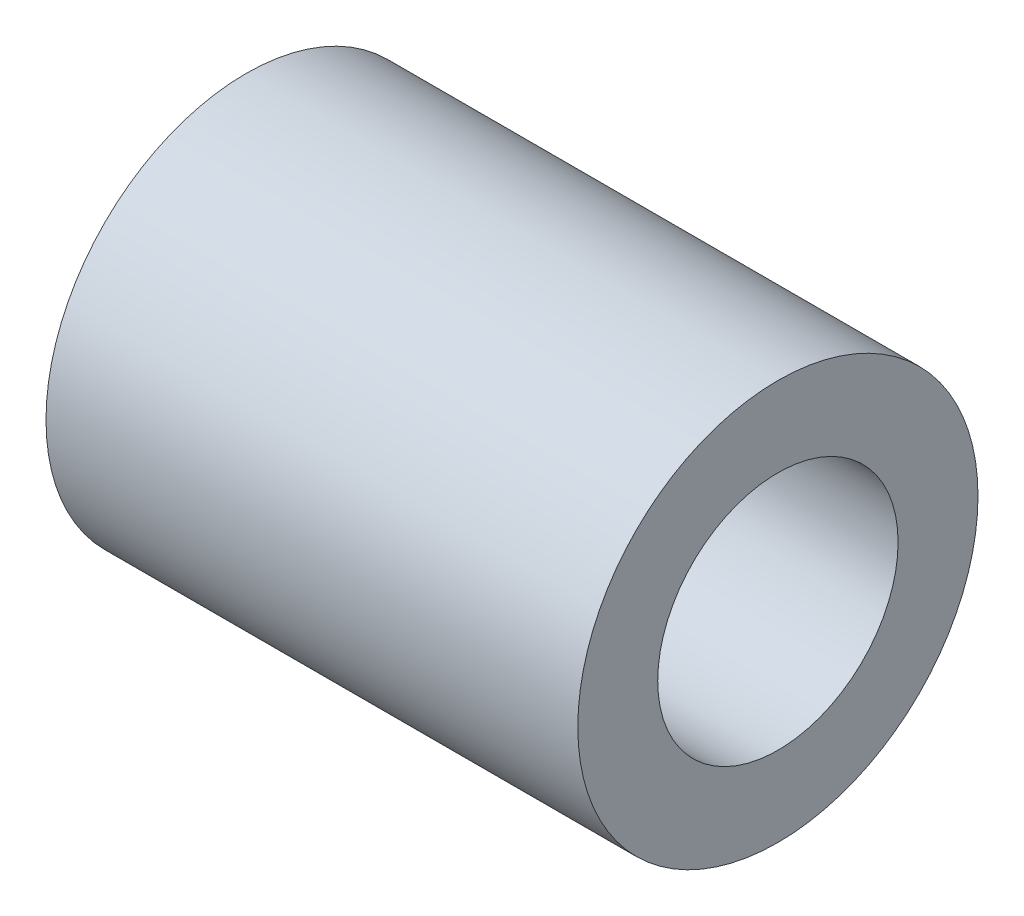
from build123d import *

# Parameters (mm, degrees)
CROQUIS1_R              = 13.32
CROQUIS1_R_2            = 8
SALIENTE_EXTRUIR1_DEPTH = 35.4


with BuildPart() as part:
    # Croquis1 → Saliente-Extruir1 (new body)
    with BuildSketch(Plane(origin=(0, 0, 0), x_dir=(0, 0, -1), z_dir=(1, 0, 0))):
        Circle(CROQUIS1_R)
        Circle(CROQUIS1_R_2, mode=Mode.SUBTRACT)
    extrude(amount=SALIENTE_EXTRUIR1_DEPTH)


solid = part.part
